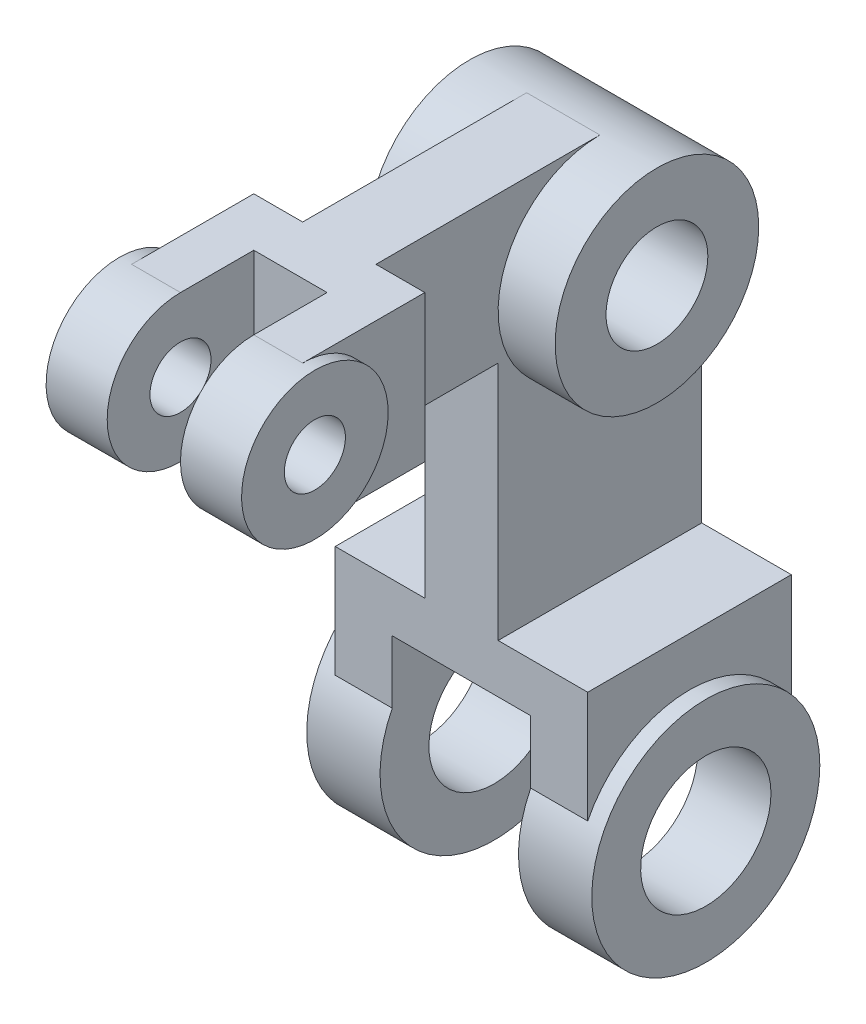
from build123d import *

# Parameters (mm, degrees)
BOSS_EXTRUDE1_DEPTH     = 9
SKETCH1_3_R             = 12.500000000000007
BOSS_EXTRUDE2_DEPTH     = 23
SKETCH1_5_R             = 16
BOSS_EXTRUDE3_DEPTH     = 35
BOSS_EXTRUDE4_DEPTH     = 31
BOSS_EXTRUDE5_DEPTH     = 21
SKETCH1_8_R             = 7.500000000000014
BOSS_EXTRUDE6_DEPTH     = 24
CUT_EXTRUDE1_DEPTH      = 174.37531542869652
CUT_EXTRUDE1_DEPTH_BACK = 174.37531542869652
CUT_EXTRUDE2_DEPTH      = 196.9668339286013
CUT_EXTRUDE2_DEPTH_BACK = 196.9668339286013


with BuildPart() as part:
    # Sketch1 → Boss-Extrude1 (new, symmetric)
    with BuildSketch(Plane(origin=(0, 0, 0), x_dir=(0, 0, -1), z_dir=(1, 0, 0))):
        with BuildLine():
            Line((0, 135), (-55, 134.99999999999997))
            Line((-55, 135), (-54.99999999999999, 99))
            Line((-54.99999999999999, 99), (-24.999999999999993, 99))
            Line((-24.999999999999996, 99), (-24.99999999999999, 40))
            Line((-24.999999999999993, 40), (25.000000000000007, 40))
            Line((25.000000000000014, 40), (25.000000000000004, 110))
            ThreePointArc((25.000000000000004, 110), (-17.67766952966369, 92.32233047033631), (-3.16e-15, 135))
        make_face()
    extrude(amount=BOSS_EXTRUDE1_DEPTH, both=True)

    # Sketch1_3 → Boss-Extrude2 (add, symmetric)
    with BuildSketch(Plane(origin=(0, 0, 0), x_dir=(0, 0, -1), z_dir=(1, 0, 0))):
        with BuildLine():
            ThreePointArc((-2.58e-15, 135), (-17.67766952966369, 127.67766952966369), (-25.000000000000004, 110))
            ThreePointArc((-25.000000000000004, 110), (-3.16e-15, 85), (25.000000000000004, 110))
            ThreePointArc((25.000000000000004, 110), (17.67766952966369, 127.67766952966369), (-2.58e-15, 135))
        make_face()
        with Locations((1.44e-15, 110)):
            Circle(SKETCH1_3_R, mode=Mode.SUBTRACT)
    extrude(amount=BOSS_EXTRUDE2_DEPTH, both=True)



with BuildPart() as body_2:
    # Sketch1_5 → Boss-Extrude3 (new, symmetric)
    with BuildSketch(Plane(origin=(0, 0, 0), x_dir=(0, 0, -1), z_dir=(1, 0, 0))):
        with BuildLine():
            ThreePointArc((25.000000000000018, 12.609520212918458), (3.902e-14, 28), (-24.999999999999982, 12.609520212918525))
            ThreePointArc((-24.999999999999982, 12.609520212918525), (-6.480740698407893, -27.239676943752464), (28, -6.86e-15))
            ThreePointArc((28, 0), (27.239676943752475, 6.480740698407842), (25.000000000000018, 12.609520212918458))
        make_face()
        Circle(SKETCH1_5_R, mode=Mode.SUBTRACT)
    extrude(amount=BOSS_EXTRUDE3_DEPTH, both=True)


with BuildPart() as part_1:
    add(part.part)

    add(body_2.part)  # Boss-Extrude4 merges body 2
    # Sketch1_6 → Boss-Extrude4 (add, symmetric)
    with BuildSketch(Plane(origin=(0, 0, 0), x_dir=(0, 0, -1), z_dir=(1, 0, 0))):
        with BuildLine():
            Line((-24.99999999999999, 40), (-24.999999999999986, 12.609520212918525))
            ThreePointArc((-24.999999999999986, 12.60952021291852), (3.375e-14, 28), (25.000000000000018, 12.609520212918461))
            Line((25.000000000000018, 12.609520212918454), (25.000000000000014, 40))
            Line((25.000000000000007, 40), (-24.999999999999993, 40))
        make_face()
    extrude(amount=BOSS_EXTRUDE4_DEPTH, both=True)

    # Sketch1_7 → Boss-Extrude5 (add, symmetric)
    with BuildSketch(Plane(origin=(0, 0, 0), x_dir=(0, 0, -1), z_dir=(1, 0, 0))):
        with BuildLine():
            Line((-84.99999999999999, 98.99999999999999), (-54.99999999999999, 99))
            Line((-54.99999999999999, 99), (-55, 135))
            Line((-55, 134.99999999999997), (-84.99999999999999, 134.99999999999997))
            ThreePointArc((-84.99999999999999, 135.00000000000003), (-72.27207793864211, 129.72792206135787), (-66.99999999999997, 117))
            ThreePointArc((-66.99999999999997, 117), (-72.27207793864213, 104.27207793864213), (-84.99999999999999, 98.99999999999999))
        make_face()
    extrude(amount=BOSS_EXTRUDE5_DEPTH, both=True)

    # Sketch1_8 → Boss-Extrude6 (add, symmetric)
    with BuildSketch(Plane(origin=(0, 0, 0), x_dir=(0, 0, -1), z_dir=(1, 0, 0))):
        with BuildLine():
            ThreePointArc((-84.99999999999999, 135.00000000000003), (-103, 117), (-84.99999999999999, 98.99999999999999))
            ThreePointArc((-84.99999999999999, 98.99999999999999), (-72.27207793864213, 104.27207793864213), (-66.99999999999997, 117))
            ThreePointArc((-66.99999999999997, 117), (-72.27207793864211, 129.72792206135787), (-84.99999999999999, 135.00000000000003))
        make_face()
        with Locations((-84.99999999999999, 117)):
            Circle(SKETCH1_8_R, mode=Mode.SUBTRACT)
    extrude(amount=BOSS_EXTRUDE6_DEPTH, both=True)

    # Sketch2 → Cut-Extrude1 (cut, two sides: drawn at the far end of the back side and taken through both)
    with BuildSketch(Plane.XY.offset(-CUT_EXTRUDE1_DEPTH_BACK)):
        Polygon((-17.000000000000007, 27.999999999999996), (17.000000000000007, 27.999999999999996), (17, -28), (-17, -28), align=None)
    extrude(amount=CUT_EXTRUDE1_DEPTH + CUT_EXTRUDE1_DEPTH_BACK, mode=Mode.SUBTRACT)

    # Sketch3 → Cut-Extrude2 (cut, two sides: drawn at the far end of the back side and taken through both)
    with BuildSketch(Plane(origin=(0, 135, 4.408e-14), x_dir=(1, 0, 0), z_dir=(0, 1, 3.3e-16)).offset(-CUT_EXTRUDE2_DEPTH_BACK)):
        Polygon((-8.999999999999991, -66.99999999999994), (9.000000000000005, -66.99999999999994), (9.000000000000005, -102.99999999999997), (-8.999999999999986, -102.99999999999997), align=None)
    extrude(amount=CUT_EXTRUDE2_DEPTH + CUT_EXTRUDE2_DEPTH_BACK, mode=Mode.SUBTRACT)


solid = part_1.part
